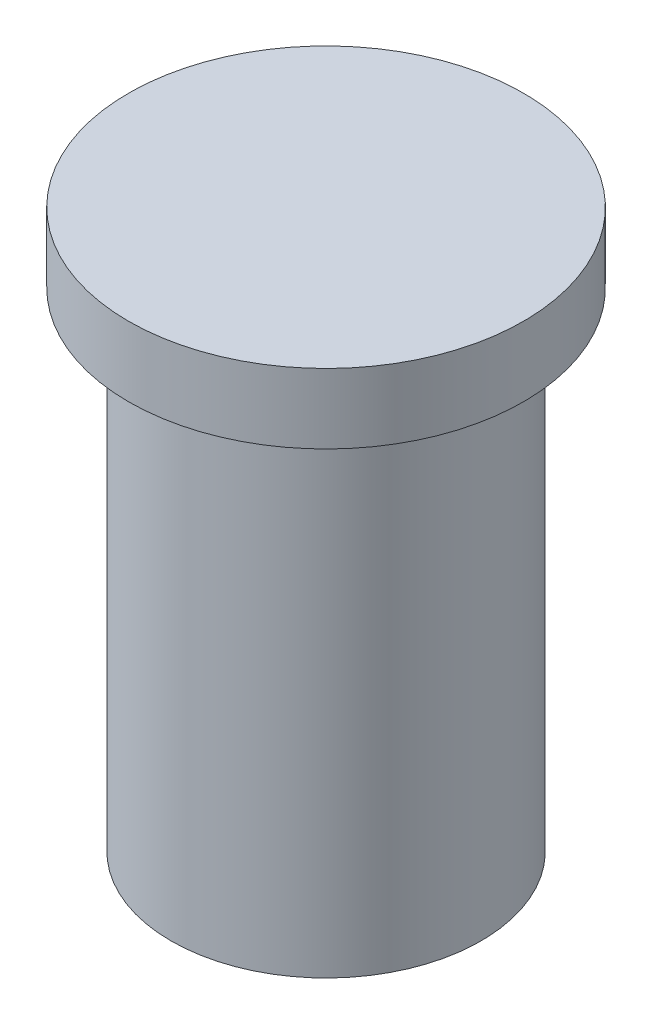
from build123d import *

# Parameters (mm, degrees)
SKETCH1_R           = 28.321
SKETCH1_R_2         = 22.225
BOSS_EXTRUDE1_DEPTH = 10
SKETCH1_2_R         = 22.225
BOSS_EXTRUDE2_DEPTH = 70
SKETCH1_3_R         = 22.225
BOSS_EXTRUDE3_DEPTH = 10


with BuildPart() as part:
    # Sketch1 → Boss-Extrude1 (new body)
    with BuildSketch(Plane(origin=(0, 0, 0), x_dir=(1, 0, 0), z_dir=(0, 1, 0))):
        Circle(SKETCH1_R)
        Circle(SKETCH1_R_2, mode=Mode.SUBTRACT)
    extrude(amount=BOSS_EXTRUDE1_DEPTH)



with BuildPart() as body_2:
    # Sketch1_2 → Boss-Extrude2 (new body)
    with BuildSketch(Plane(origin=(0, 0, 0), x_dir=(1, 0, 0), z_dir=(0, 1, 0))):
        Circle(SKETCH1_2_R)
    extrude(amount=-BOSS_EXTRUDE2_DEPTH)


with BuildPart() as part_1:
    add(part.part)

    add(body_2.part)  # Boss-Extrude3 merges body 2
    # Sketch1_3 → Boss-Extrude3 (add)
    with BuildSketch(Plane(origin=(0, 0, 0), x_dir=(1, 0, 0), z_dir=(0, 1, 0))):
        Circle(SKETCH1_3_R)
    extrude(amount=BOSS_EXTRUDE3_DEPTH)


solid = part_1.part
